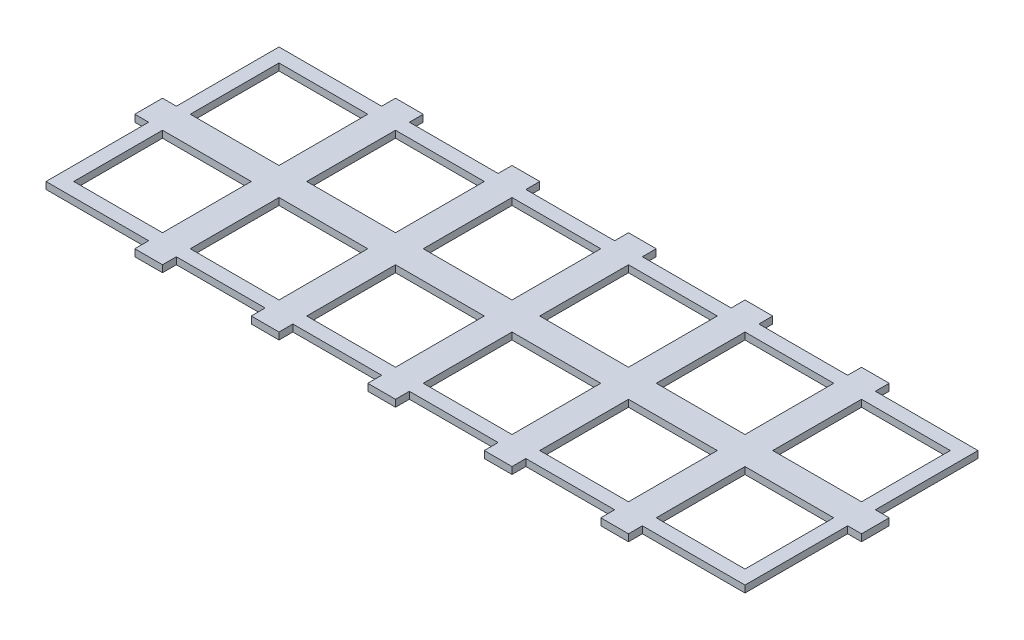
from build123d import *

# Parameters (mm, degrees)
CROQUIS1_W              = 64
CROQUIS1_H              = 64
SALIENTE_EXTRUIR1_DEPTH = 5


with BuildPart() as part:
    # Croquis1 → Saliente-Extruir1 (new body)
    with BuildSketch(Plane(origin=(0, 0, 0), x_dir=(1, 0, 0), z_dir=(0, 1, 0))):
        Polygon((-10, -10), (64, -10), (64, -20), (84, -20), (84, -10), (148, -10), (148, -20), (168, -20), (168, -10), (232, -10), (232, -20), (252, -20), (252, -10), (316, -10), (316, -20), (336, -20), (336, -10), (400, -10), (400, -20), (420, -20), (420, -10), (494, -10), (494, 64), (504, 64), (504, 84), (494, 84), (494, 158), (420, 158), (420, 168), (400, 168), (400, 158), (336, 158), (336, 168), (316, 168), (316, 158), (252, 158), (252, 168), (232, 168), (232, 158), (168, 158), (168, 168), (148, 168), (148, 158), (84, 158), (84, 168), (64, 168), (64, 158), (-10, 158), (-10, 84), (-20, 84), (-20, 64), (-10, 64), align=None)
        with Locations((32, 32)):
            Rectangle(CROQUIS1_W, CROQUIS1_H, mode=Mode.SUBTRACT)
        with Locations((116, 32)):
            Rectangle(CROQUIS1_W, CROQUIS1_H, mode=Mode.SUBTRACT)
        with Locations((200, 32)):
            Rectangle(CROQUIS1_W, CROQUIS1_H, mode=Mode.SUBTRACT)
        with Locations((284, 32)):
            Rectangle(CROQUIS1_W, CROQUIS1_H, mode=Mode.SUBTRACT)
        with Locations((368, 32)):
            Rectangle(CROQUIS1_W, CROQUIS1_H, mode=Mode.SUBTRACT)
        with Locations((452, 32)):
            Rectangle(CROQUIS1_W, CROQUIS1_H, mode=Mode.SUBTRACT)
        with Locations((116, 116)):
            Rectangle(CROQUIS1_W, CROQUIS1_H, mode=Mode.SUBTRACT)
        with Locations((200, 116)):
            Rectangle(CROQUIS1_W, CROQUIS1_H, mode=Mode.SUBTRACT)
        with Locations((284, 116)):
            Rectangle(CROQUIS1_W, CROQUIS1_H, mode=Mode.SUBTRACT)
        with Locations((368, 116)):
            Rectangle(CROQUIS1_W, CROQUIS1_H, mode=Mode.SUBTRACT)
        with Locations((452, 116)):
            Rectangle(CROQUIS1_W, CROQUIS1_H, mode=Mode.SUBTRACT)
        with Locations((32, 116)):
            Rectangle(CROQUIS1_W, CROQUIS1_H, mode=Mode.SUBTRACT)
    extrude(amount=SALIENTE_EXTRUIR1_DEPTH)


solid = part.part
